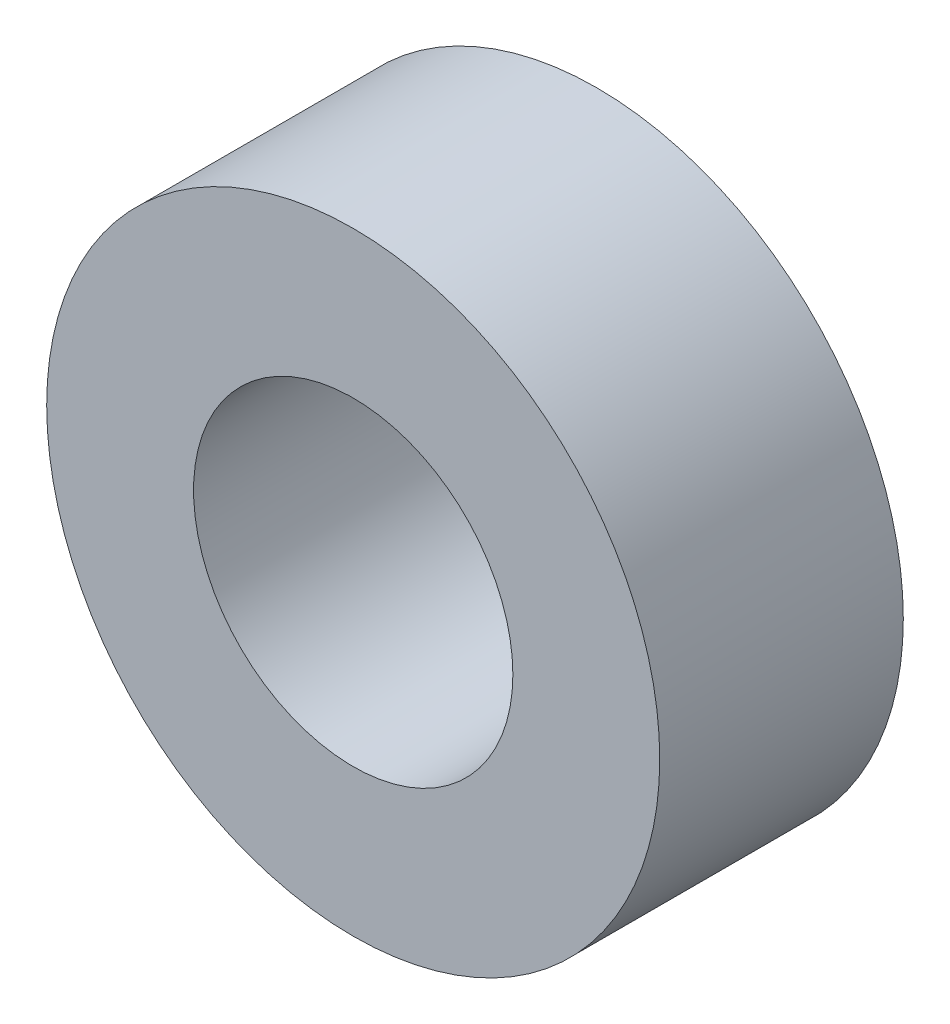
from build123d import *

# Parameters (mm, degrees)
SKETCH2_R           = 2.4
SKETCH2_R_2         = 1.25
BOSS_EXTRUDE1_DEPTH = 1.907


with BuildPart() as part:
    # Sketch2 → Boss-Extrude1 (new body)
    with BuildSketch(Plane.XY):
        Circle(SKETCH2_R)
        Circle(SKETCH2_R_2, mode=Mode.SUBTRACT)
    extrude(amount=BOSS_EXTRUDE1_DEPTH)


solid = part.part
